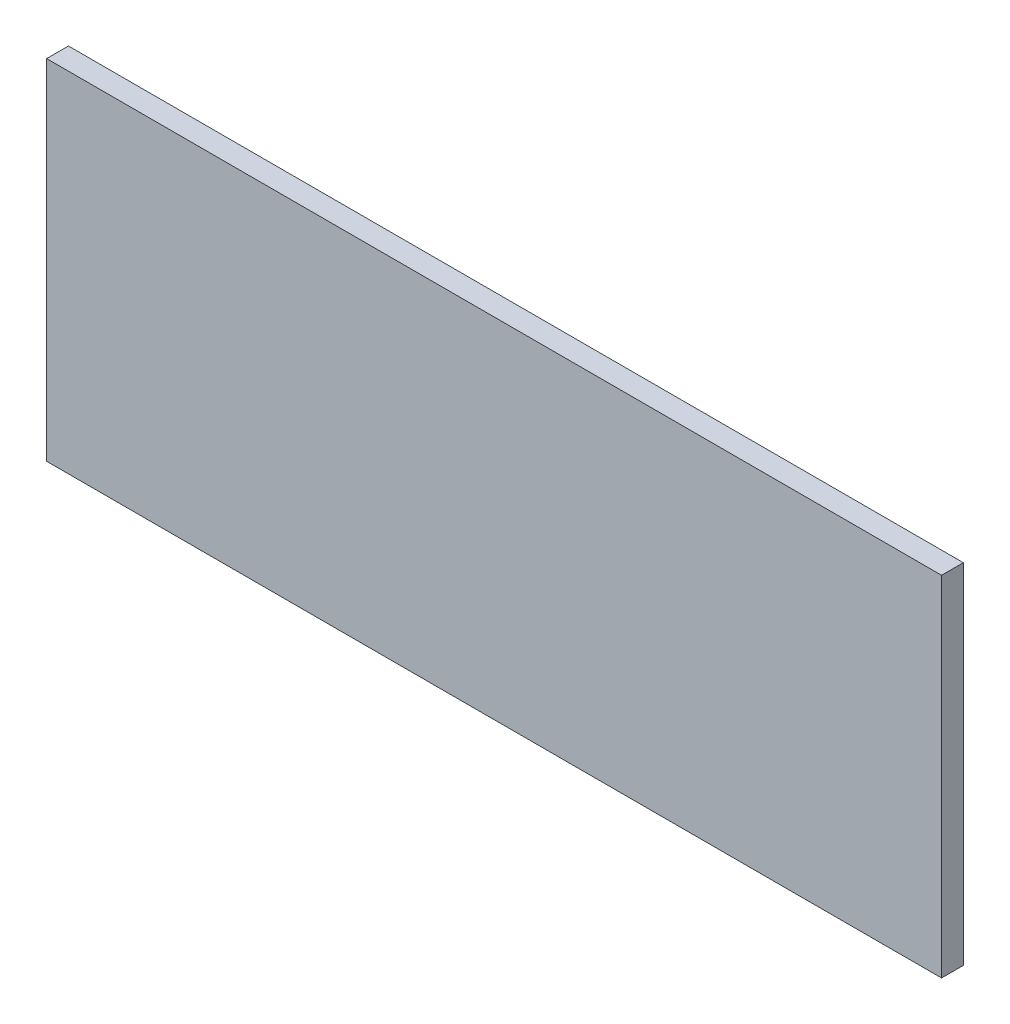
from build123d import *

# Parameters (mm, degrees)
SKETCH1_W           = 739
SKETCH1_H           = 288
BOSS_EXTRUDE1_DEPTH = 18


with BuildPart() as part:
    # Sketch1 → Boss-Extrude1 (new body)
    with BuildSketch(Plane.XY):
        Rectangle(SKETCH1_W, SKETCH1_H)
    extrude(amount=BOSS_EXTRUDE1_DEPTH)


solid = part.part
